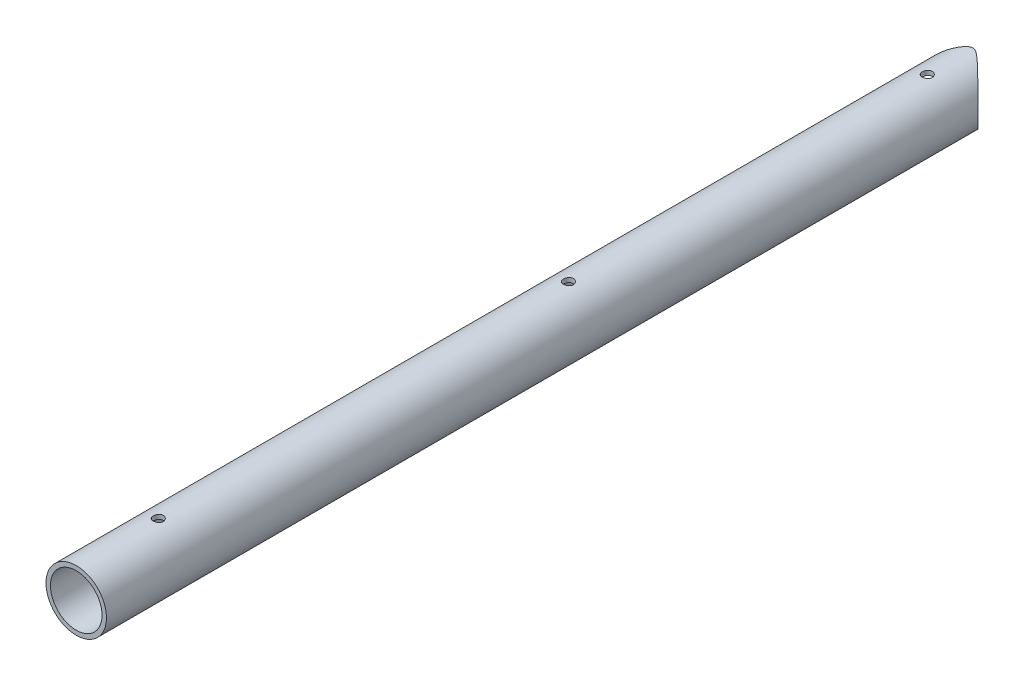
from build123d import *

# Parameters (mm, degrees)
SKETCH1_R               = 9.36
SKETCH1_R_2             = 7.99
EXTRUDE1_DEPTH          = 279.4
SKETCH2_R               = 9.525
CUT_EXTRUDE1_DEPTH      = 10.36
CUT_EXTRUDE1_DEPTH_BACK = 10.36
SKETCH3_R               = 1.55
CUT_EXTRUDE2_DEPTH      = 10.3600001
CUT_EXTRUDE2_DEPTH_BACK = 10.3600001
SKETCH4_R               = 3.5
CUT_EXTRUDE3_DEPTH      = 10.3600001


with BuildPart() as part:
    # Sketch1 → Extrude1 (new body)
    with BuildSketch(Plane.XY):
        Circle(SKETCH1_R)
        Circle(SKETCH1_R_2, mode=Mode.SUBTRACT)
    extrude(amount=EXTRUDE1_DEPTH)

    # Sketch2 → Cut-Extrude1 (cut, two sides)
    with BuildSketch(Plane(origin=(0, 0, 0), x_dir=(0, 0, -1), z_dir=(1, 0, 0))) as cut_extrude1_sk:
        Circle(SKETCH2_R)
    extrude(amount=CUT_EXTRUDE1_DEPTH, mode=Mode.SUBTRACT)
    extrude(cut_extrude1_sk.sketch, amount=-CUT_EXTRUDE1_DEPTH_BACK, mode=Mode.SUBTRACT)

    # Sketch3 → Cut-Extrude2 (cut, two sides)
    with BuildSketch(Plane(origin=(0, 0, 0), x_dir=(1, 0, 0), z_dir=(0, 1, 0))) as cut_extrude2_sk:
        with Locations((0, -15.88)):
            Circle(SKETCH3_R)
        with Locations((0, -127)):
            Circle(SKETCH3_R)
        with Locations((0, -254)):
            Circle(SKETCH3_R)
    extrude(amount=CUT_EXTRUDE2_DEPTH, mode=Mode.SUBTRACT)
    extrude(cut_extrude2_sk.sketch, amount=-CUT_EXTRUDE2_DEPTH_BACK, mode=Mode.SUBTRACT)

    # Sketch4 → Cut-Extrude3 (cut, through all)
    with BuildSketch(Plane(origin=(0, 0, 0), x_dir=(0, 0, -1), z_dir=(1, 0, 0))):
        with Locations((-127, 0)):
            Circle(SKETCH4_R)
        with Locations((-254, 0)):
            Circle(SKETCH4_R)
    extrude(amount=-CUT_EXTRUDE3_DEPTH, mode=Mode.SUBTRACT)


solid = part.part
